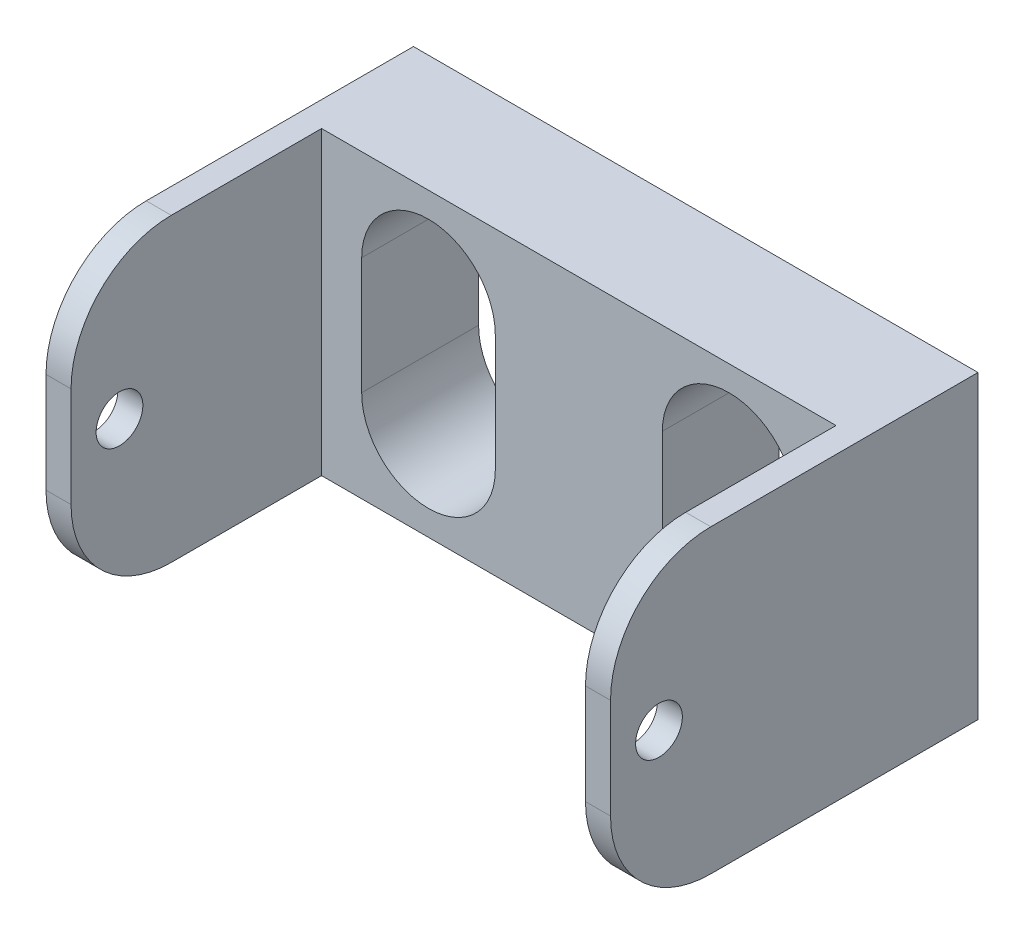
from build123d import *

# Parameters (mm, degrees)
SKETCH1_W           = 33.8
SKETCH1_H           = 18
BOSS_EXTRUDE1_DEPTH = 7
SKETCH2_W           = 1.5
SKETCH2_H           = 18
BOSS_EXTRUDE2_DEPTH = 15
SKETCH3_R           = 1.4
CUT_EXTRUDE1_DEPTH  = 34.8
FILLET1_R           = 6


with BuildPart() as part:
    # Sketch1 → Boss-Extrude1 (new body)
    with BuildSketch(Plane.XY):
        Rectangle(SKETCH1_W, SKETCH1_H)
        with BuildLine():
            Line((-5, 3.5), (-5, -3.5))
            ThreePointArc((-5, -3.5), (-9, -7.5), (-13, -3.5))
            Line((-13, -3.5), (-13, 3.5))
            ThreePointArc((-13, 3.5), (-9, 7.5), (-5, 3.5))
        make_face(mode=Mode.SUBTRACT)
        with BuildLine():
            Line((13, 3.5), (13, -3.5))
            ThreePointArc((13, -3.5), (9, -7.5), (5, -3.5))
            Line((5, -3.5), (5, 3.5))
            ThreePointArc((5, 3.5), (9, 7.5), (13, 3.5))
        make_face(mode=Mode.SUBTRACT)
    extrude(amount=BOSS_EXTRUDE1_DEPTH)

    # Sketch2 → Boss-Extrude2 (add)
    with BuildSketch(Plane.XY.offset(7)):
        with Locations((-16.15, 0)):
            Rectangle(SKETCH2_W, SKETCH2_H)
        with Locations((16.15, 0)):
            Rectangle(SKETCH2_W, SKETCH2_H)
    extrude(amount=BOSS_EXTRUDE2_DEPTH)

    # Sketch3 → Cut-Extrude1 (cut, through all)
    with BuildSketch(Plane(origin=(16.9, 0, 0), x_dir=(0, 0, -1), z_dir=(1, 0, 0))):
        with Locations((-19.1, 0)):
            Circle(SKETCH3_R)
    extrude(amount=-CUT_EXTRUDE1_DEPTH, mode=Mode.SUBTRACT)

    # Fillet1
    fillet1_edges = [part.edges().sort_by_distance(p)[0] for p in [
        (16.15, -9, 22),
        (-16.15, -9, 22),
        (-16.15, 9, 22),
        (16.15, 9, 22),
    ]]
    fillet(fillet1_edges, radius=FILLET1_R)


solid = part.part
